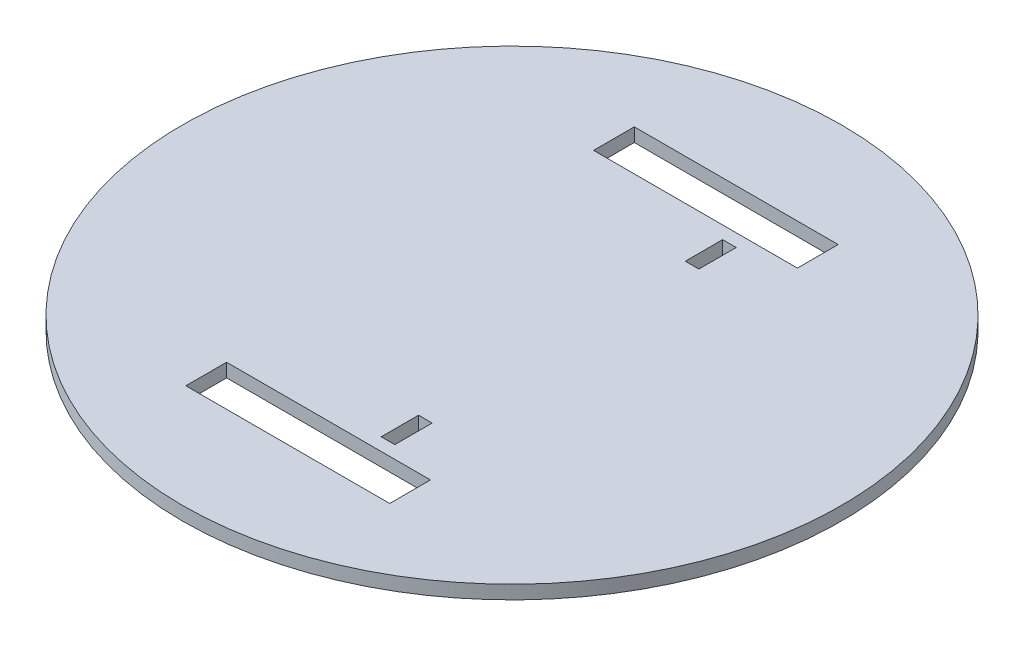
from build123d import *

# Parameters (mm, degrees)
SKETCH1_R           = 97
BOSS_EXTRUDE1_DEPTH = 4
SKETCH2_W           = 60
SKETCH2_H           = 12
CUT_EXTRUDE1_DEPTH  = 10
SKETCH3_W           = 4
SKETCH3_H           = 11
CUT_EXTRUDE2_DEPTH  = 10


with BuildPart() as part:
    # Sketch1 → Boss-Extrude1 (new body)
    with BuildSketch(Plane(origin=(0, 0, 0), x_dir=(1, 0, 0), z_dir=(0, 1, 0))):
        with Locations(Location((0, 0, 0), (0, 0, 270))):  # turned: the seam where the file's is
            Circle(SKETCH1_R)
    extrude(amount=BOSS_EXTRUDE1_DEPTH)

    # Sketch2 → Cut-Extrude1 (cut)
    with BuildSketch(Plane(origin=(0, 4, 0), x_dir=(1, 0, 0), z_dir=(0, 1, 0))):
        with Locations((0, -60)):
            Rectangle(SKETCH2_W, SKETCH2_H)
        with Locations((0, 60)):
            Rectangle(SKETCH2_W, SKETCH2_H)
    extrude(amount=-CUT_EXTRUDE1_DEPTH, mode=Mode.SUBTRACT)

    # Sketch3 → Cut-Extrude2 (cut)
    with BuildSketch(Plane(origin=(0, 4, 0), x_dir=(1, 0, 0), z_dir=(0, 1, 0))):
        with Locations((13.75, -44.75)):
            Rectangle(SKETCH3_W, SKETCH3_H)
        with Locations((13.75, 44.75)):
            Rectangle(SKETCH3_W, SKETCH3_H)
    extrude(amount=-CUT_EXTRUDE2_DEPTH, mode=Mode.SUBTRACT)


solid = part.part
